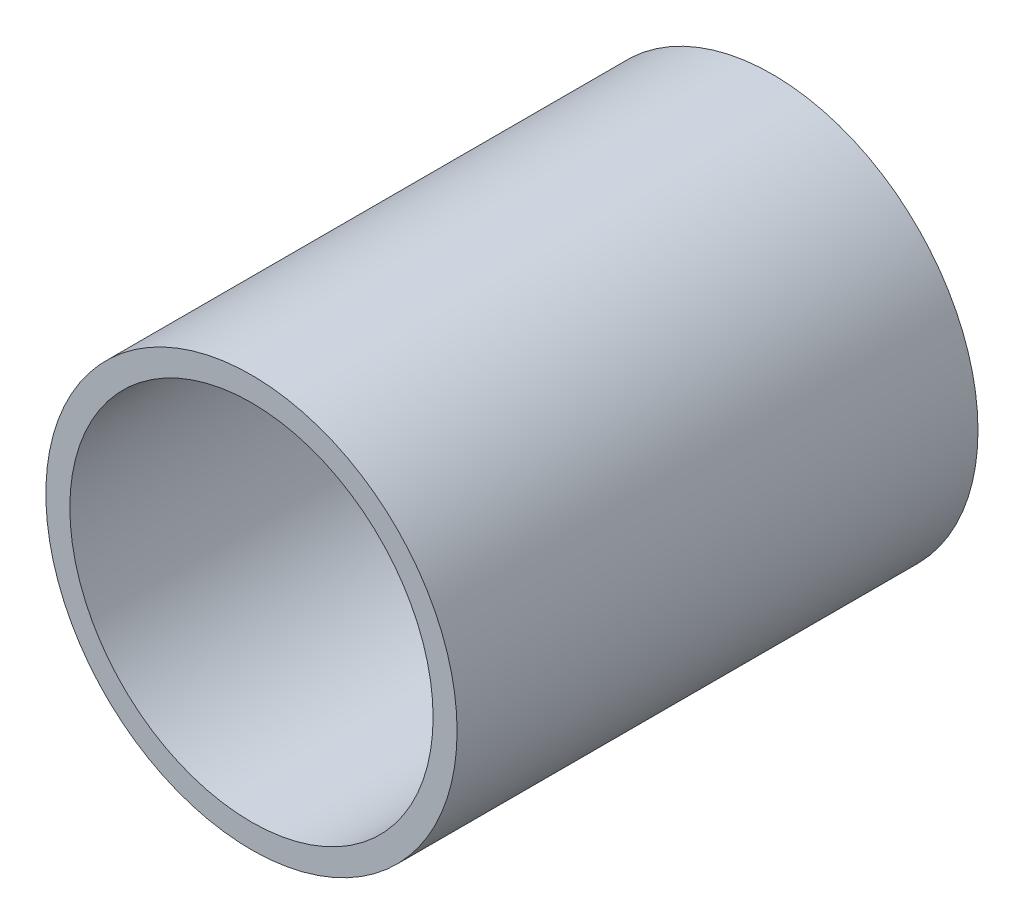
from build123d import *

# Parameters (mm, degrees)
SKETCH1_R           = 19.05
SKETCH1_R_2         = 16.8275
BOSS_EXTRUDE1_DEPTH = 48.26


with BuildPart() as part:
    # Sketch1 → Boss-Extrude1 (new body)
    with BuildSketch(Plane.XY):
        Circle(SKETCH1_R)
        Circle(SKETCH1_R_2, mode=Mode.SUBTRACT)
    extrude(amount=BOSS_EXTRUDE1_DEPTH)


solid = part.part
